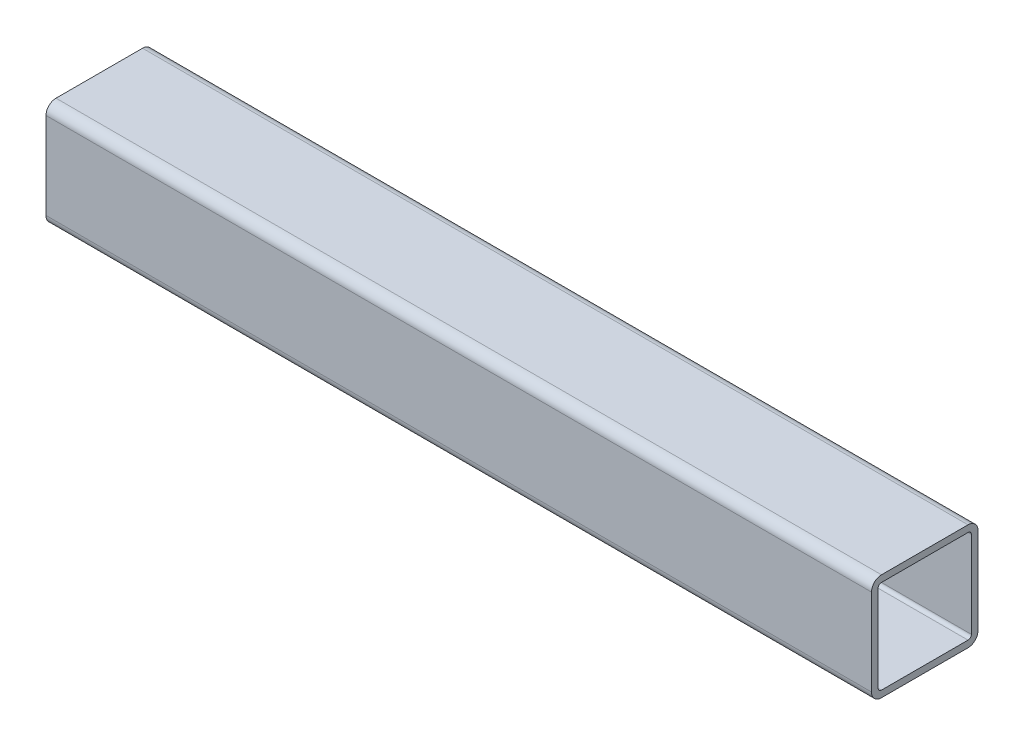
from build123d import *

# Parameters (mm, degrees)
BOSS_EXTRUDE1_DEPTH = 196.85


with BuildPart() as part:
    # Sketch1 → Boss-Extrude1 (new body, symmetric)
    with BuildSketch(Plane.YZ):
        with BuildLine():
            Line((-20.6375, 25.4), (20.6375, 25.4))
            ThreePointArc((20.6375, 25.4), (24.005096045, 24.005096045), (25.4, 20.6375))
            Line((25.4, 20.6375), (25.4, -20.6375))
            ThreePointArc((25.4, -20.6375), (24.005096045, -24.005096045), (20.6375, -25.4))
            Line((20.6375, -25.4), (-20.6375, -25.4))
            ThreePointArc((-20.6375, -25.4), (-24.005096045, -24.005096045), (-25.4, -20.6375))
            Line((-25.4, -20.6375), (-25.4, 20.6375))
            ThreePointArc((-25.4, 20.6375), (-24.005096045, 24.005096045), (-20.6375, 25.4))
        make_face()
        with BuildLine():
            Line((-20.6375, 22.225), (20.6375, 22.225))
            ThreePointArc((20.6375, 22.225), (21.760032015, 21.760032015), (22.225, 20.6375))
            Line((22.225, 20.6375), (22.225, -20.6375))
            ThreePointArc((22.225, -20.6375), (21.760032015, -21.760032015), (20.6375, -22.225))
            Line((20.6375, -22.225), (-20.6375, -22.225))
            ThreePointArc((-20.6375, -22.225), (-21.760032015, -21.760032015), (-22.225, -20.6375))
            Line((-22.225, -20.6375), (-22.225, 20.6375))
            ThreePointArc((-22.225, 20.6375), (-21.760032015, 21.760032015), (-20.6375, 22.225))
        make_face(mode=Mode.SUBTRACT)
    extrude(amount=BOSS_EXTRUDE1_DEPTH, both=True)


solid = part.part
